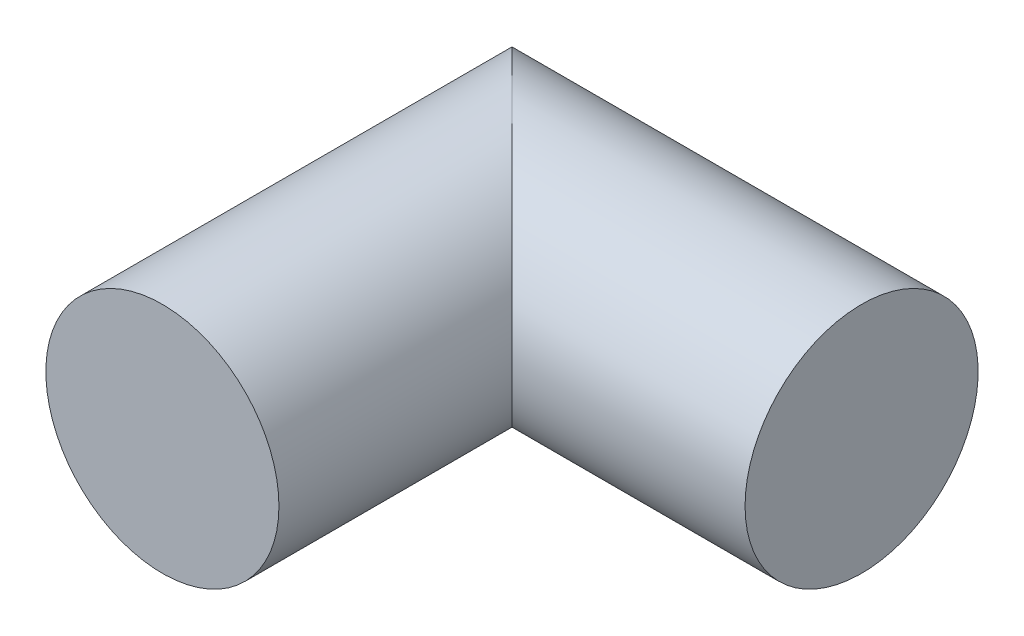
from build123d import *

# Parameters (mm, degrees)
SKETCH3_R = 5


with BuildPart() as part:
    # Sweep1: sweep along a curve in space
    with BuildLine() as sweep1_path:
        Line((0, 0, 0), (-15, 0, 0))
        Line((-15, 0, 0), (-15, 0, 15))
    # Sketch3 → Sweep1 (sweep)
    with BuildSketch(Plane.ZY):
        Circle(SKETCH3_R)
    sweep(path=sweep1_path.line, transition=Transition.RIGHT)


solid = part.part
